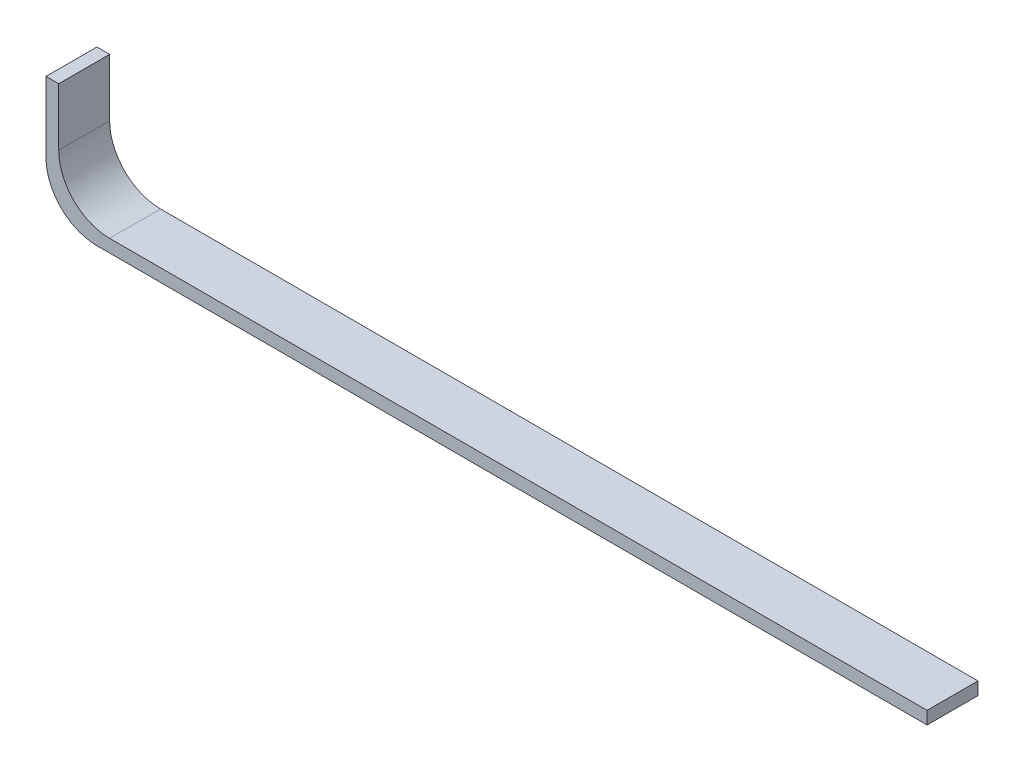
from build123d import *

# Parameters (mm, degrees)
EXTRUDE1_DEPTH = 2.54


with BuildPart() as part:
    # Sketch1 → Extrude1 (new body)
    with BuildSketch(Plane.XY):
        with BuildLine():
            Line((0, 0), (0, -3.50696882))
            ThreePointArc((0, -3.50696882), (0.743948776, -5.303020044), (2.54, -6.04696882))
            Line((2.54, -6.04696882), (43.966543552, -6.04696882))
            Line((43.966543552, -6.04696882), (43.966543552, -5.41196882))
            Line((43.966543552, -5.41196882), (3.175, -5.41196882))
            ThreePointArc((3.175, -5.41196882), (1.378948776, -4.668020044), (0.635, -2.87196882))
            Line((0.635, -2.87196882), (0.635, 0))
            Line((0.635, 0), (0, 0))
        make_face()
    extrude(amount=EXTRUDE1_DEPTH)


solid = part.part
